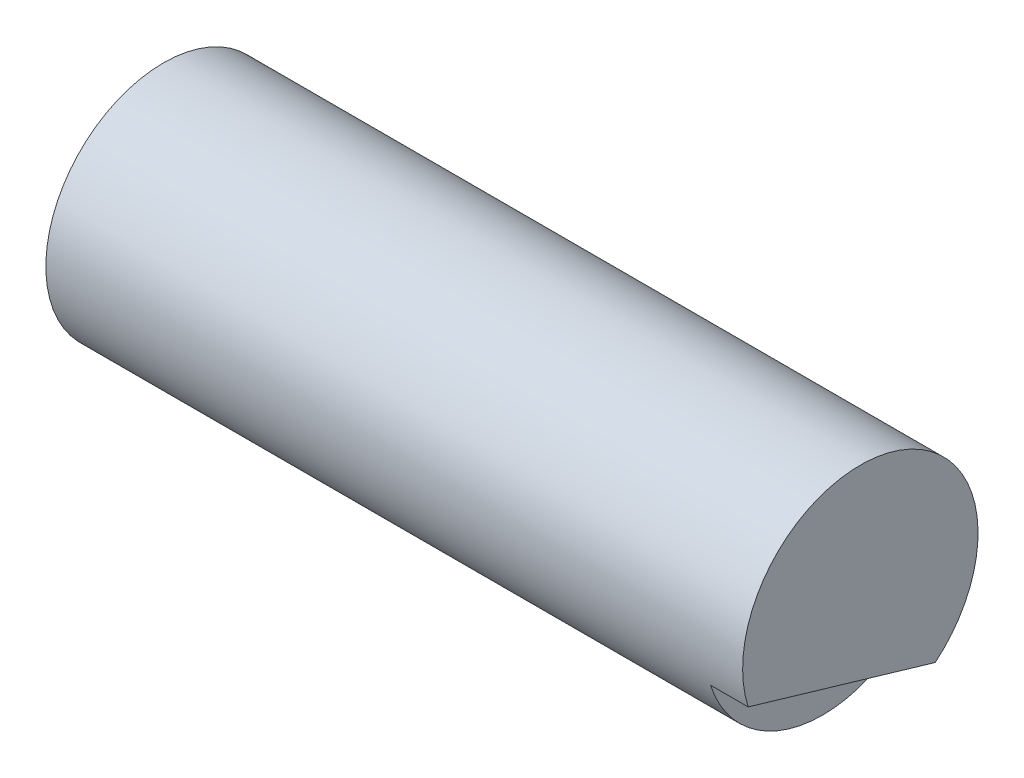
from build123d import *

# Parameters (mm, degrees)
SKETCH_1_R          = 12.5
EXTRUDE_1_DEPTH     = 74
CUT_EXTRUDE_1_DEPTH = 4


with BuildPart() as part:
    # 草图1 → 凸台-拉伸1 (new body)
    with BuildSketch(Plane.ZY.offset(5)):
        with Locations((-2475, 109.950168602)):
            Circle(SKETCH_1_R)
    extrude(amount=-EXTRUDE_1_DEPTH)

    # 草图3 → 切除-拉伸1 (cut)
    with BuildSketch(Plane(origin=(65, 0, 0), x_dir=(0, 0, -1), z_dir=(1, 0, 0))):
        with BuildLine():
            Line((2482.958697764, 100.311230388), (2463.088913737, 106.158595838))
            ThreePointArc((2463.088913737, 106.158595838), (2471.471081697, 97.958640943), (2482.958697764, 100.311230388))
        make_face()
    extrude(amount=CUT_EXTRUDE_1_DEPTH, mode=Mode.SUBTRACT)


solid = part.part
